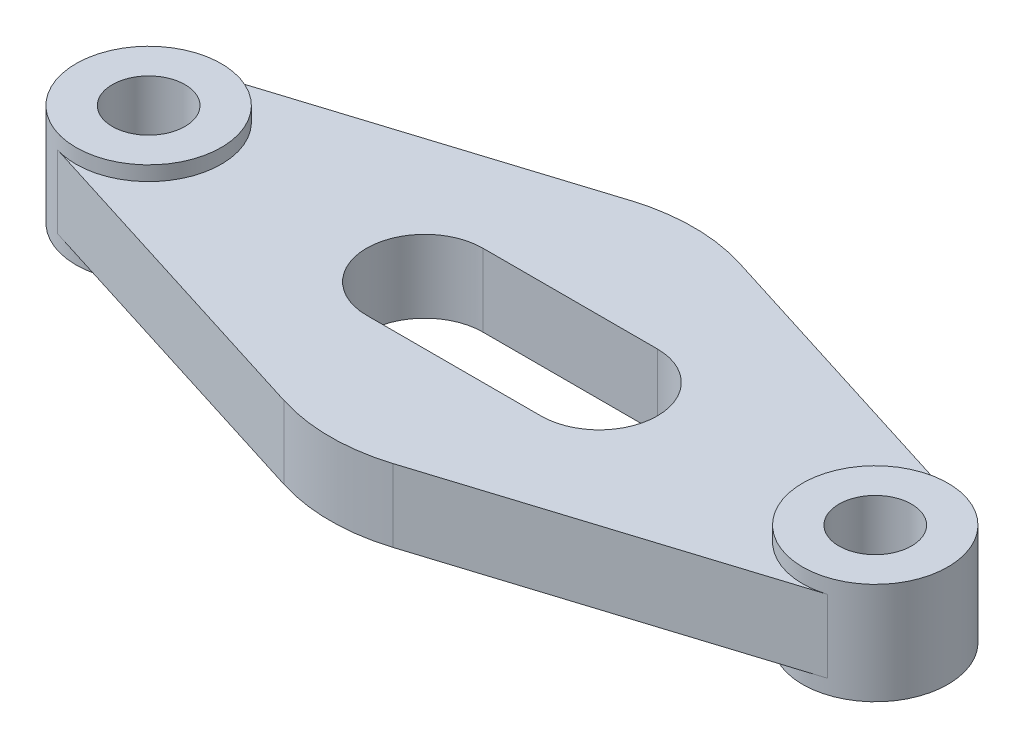
from build123d import *

# Parameters (mm, degrees)
SALIENTE_EXTRUIR1_DEPTH      = 5
SALIENTE_EXTRUIR1_DEPTH_BACK = 5
SALIENTE_EXTRUIR2_DEPTH      = 7
SALIENTE_EXTRUIR2_DEPTH_BACK = 7
CROQUIS6_3_R                 = 10
CROQUIS6_3_R_2               = 5


with BuildPart() as part:
    # Croquis6 → Saliente-Extruir1 (new, two sides: drawn at the far end of the back side and taken through both)
    with BuildSketch(Plane(origin=(0, 0, 0), x_dir=(1, 0, 0), z_dir=(0, 1, 0)).offset(-SALIENTE_EXTRUIR1_DEPTH_BACK)):
        with BuildLine():
            Line((-7.5, 23.848480035), (-53, 9.539392014))
            ThreePointArc((-53, 9.539392014), (-44.083920217, 8.062257748), (-40, 0))
            ThreePointArc((-40, 0), (-44.083920217, -8.062257748), (-53, -9.539392014))
            Line((-53, -9.539392014), (-7.5, -23.848480035))
            ThreePointArc((-7.5, -23.848480035), (0, -25), (7.5, -23.848480035))
            Line((7.5, -23.848480035), (53, -9.539392014))
            ThreePointArc((53, -9.539392014), (40, 0), (53, 9.539392014))
            Line((53, 9.539392014), (7.5, 23.848480035))
            ThreePointArc((7.5, 23.848480035), (0, 25), (-7.5, 23.848480035))
        make_face()
        with BuildLine():
            Line((12, -8), (-12, -8))
            ThreePointArc((-12, -8), (-20, 0), (-12, 8))
            Line((-12, 8), (12, 8))
            ThreePointArc((12, 8), (20, 0), (12, -8))
        make_face(mode=Mode.SUBTRACT)
    extrude(amount=SALIENTE_EXTRUIR1_DEPTH + SALIENTE_EXTRUIR1_DEPTH_BACK)

    # Croquis6_3 → Saliente-Extruir2 (add, two sides: drawn at the far end of the back side and taken through both)
    # profile 1 of 2: a face of its own
    with BuildSketch(Plane(origin=(0, 0, 0), x_dir=(1, 0, 0), z_dir=(0, 1, 0)).offset(-SALIENTE_EXTRUIR2_DEPTH_BACK)):
        with Locations((-50, 0)):
            Circle(CROQUIS6_3_R)
        with Locations((-50, 0)):
            Circle(CROQUIS6_3_R_2, mode=Mode.SUBTRACT)
    # profile 2 of 2: a face of its own
    with BuildSketch(Plane(origin=(0, 0, 0), x_dir=(1, 0, 0), z_dir=(0, 1, 0)).offset(-SALIENTE_EXTRUIR2_DEPTH_BACK)):
        with Locations((50, 0)):
            Circle(CROQUIS6_3_R)
        with Locations((50, 0)):
            Circle(CROQUIS6_3_R_2, mode=Mode.SUBTRACT)
    extrude(amount=SALIENTE_EXTRUIR2_DEPTH + SALIENTE_EXTRUIR2_DEPTH_BACK)


solid = part.part
